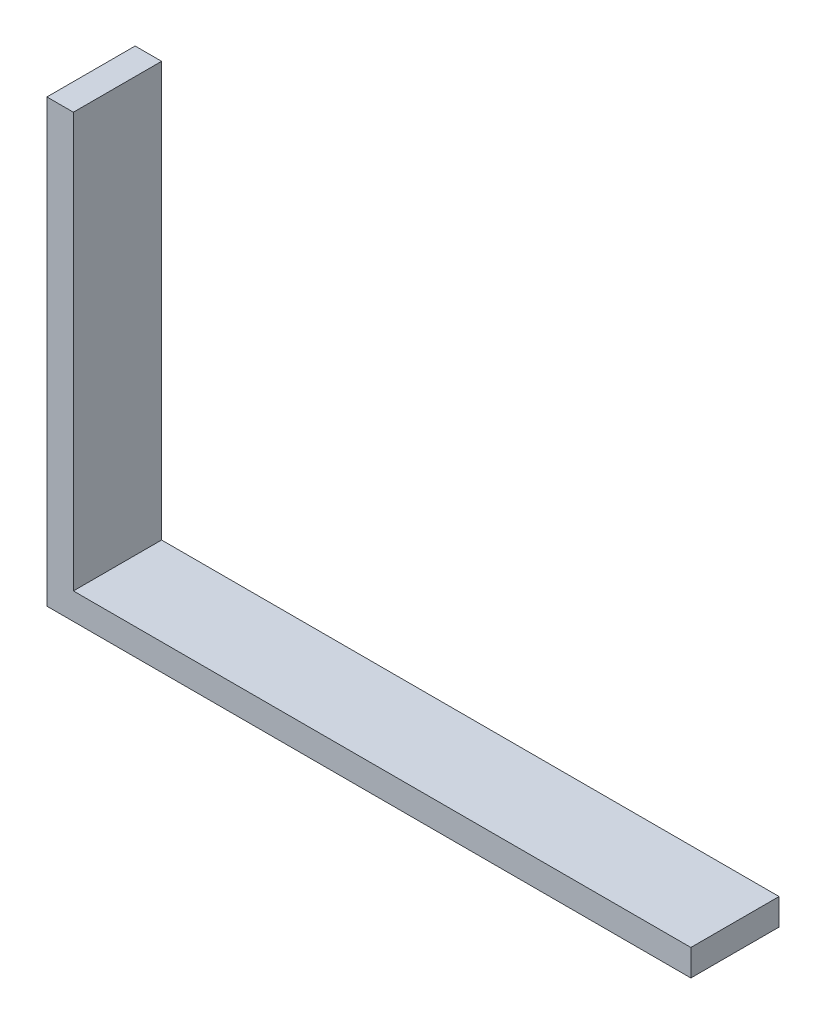
from build123d import *

# Parameters (mm, degrees)
BOSS_EXTRUDE1_DEPTH = 10


with BuildPart() as part:
    # Sketch1 → Boss-Extrude1 (new body)
    with BuildSketch(Plane.XY):
        Polygon((0, 0), (0, 50), (3, 50), (3, 3), (73, 3), (73, 0), align=None)
    extrude(amount=BOSS_EXTRUDE1_DEPTH)


solid = part.part
